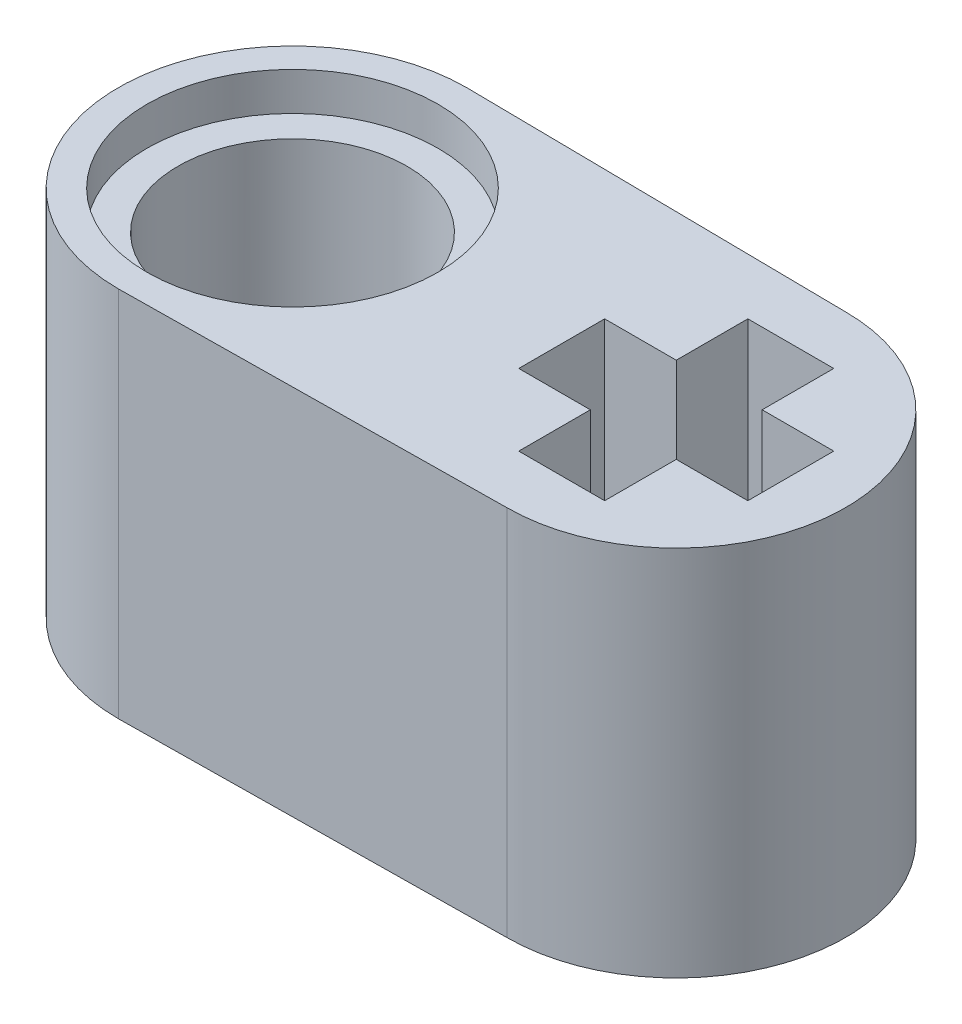
from build123d import *

# Parameters (mm, degrees)
SKETCH1_R           = 2.4
BOSS_EXTRUDE1_DEPTH = 7.8
SKETCH2_R           = 3.05
CUT_EXTRUDE1_DEPTH  = 0.8
SKETCH3_R           = 3.05
CUT_EXTRUDE2_DEPTH  = 0.8


with BuildPart() as part:
    # Sketch1 → Boss-Extrude1 (new body)
    with BuildSketch(Plane(origin=(0, 0, 0), x_dir=(1, 0, 0), z_dir=(0, 1, 0))):
        with BuildLine():
            Line((-4.07, 3.65), (3.97, 3.55))
            ThreePointArc((3.97, 3.55), (7.52, 0), (3.97, -3.55))
            Line((3.97, -3.55), (-4.07, -3.65))
            ThreePointArc((-4.07, -3.65), (-7.72, 0), (-4.07, 3.65))
        make_face()
        with Locations((-4.07, 0)):
            Circle(SKETCH1_R, mode=Mode.SUBTRACT)
        Polygon((3.07, 2.4), (3.07, 0.9), (1.57, 0.9), (1.57, -0.9), (3.07, -0.9), (3.07, -2.4), (4.87, -2.4), (4.87, -0.9), (6.37, -0.9), (6.37, 0.9), (4.87, 0.9), (4.87, 2.4), align=None, mode=Mode.SUBTRACT)
    extrude(amount=BOSS_EXTRUDE1_DEPTH)

    # Sketch2 → Cut-Extrude1 (cut)
    with BuildSketch(Plane(origin=(0, 7.8, 0), x_dir=(1, 0, 0), z_dir=(0, 1, 0))):
        with Locations((-4.07, 0)):
            Circle(SKETCH2_R)
    extrude(amount=-CUT_EXTRUDE1_DEPTH, mode=Mode.SUBTRACT)

    # Sketch3 → Cut-Extrude2 (cut)
    with BuildSketch(Plane.XZ):
        with Locations((-4.07, 0)):
            Circle(SKETCH3_R)
    extrude(amount=-CUT_EXTRUDE2_DEPTH, mode=Mode.SUBTRACT)


solid = part.part
